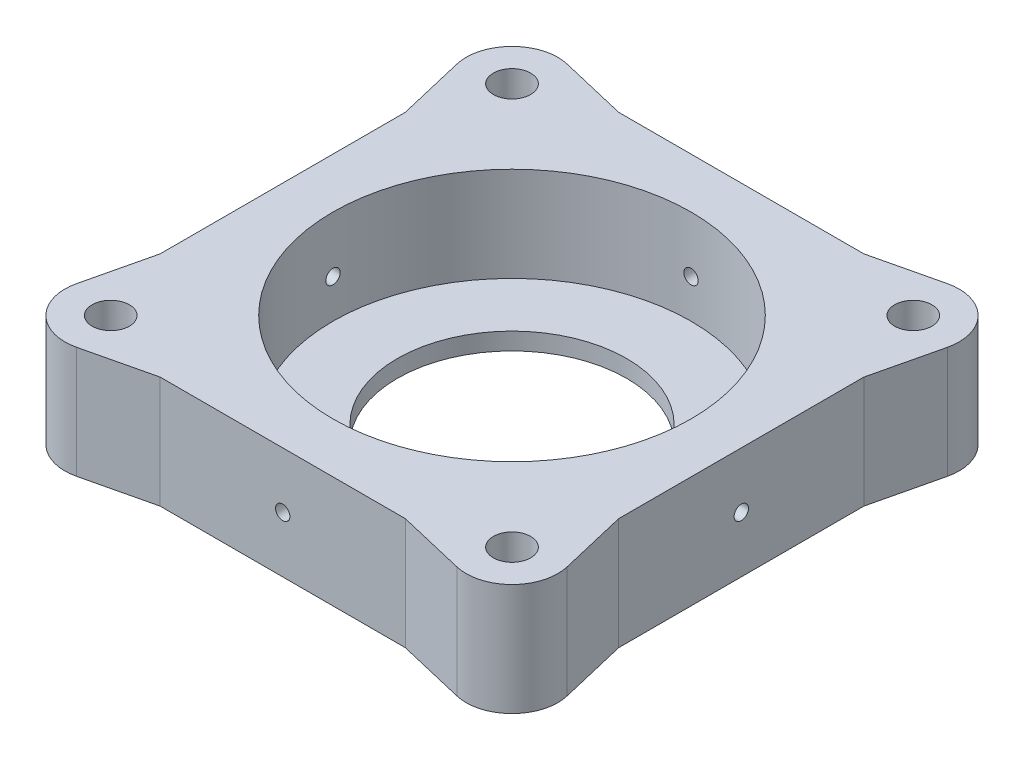
from build123d import *

# Parameters (mm, degrees)
SKETCH1_R           = 3.25
SKETCH1_R_2         = 20
BOSS_EXTRUDE1_DEPTH = 19.5
SKETCH2_R           = 31.25
CUT_EXTRUDE1_DEPTH  = 16.5
SKETCH3_R           = 5.25
CUT_EXTRUDE2_DEPTH  = 10
SKETCH4_R           = 1.25
CUT_EXTRUDE3_DEPTH  = 80
SKETCH5_R           = 1.25
CUT_EXTRUDE4_DEPTH  = 80


with BuildPart() as part:
    # Sketch1 → Boss-Extrude1 (new body)
    with BuildSketch(Plane(origin=(0, 0, 0), x_dir=(1, 0, 0), z_dir=(0, 1, 0))):
        with BuildLine():
            Line((-21.388284323, 40), (-33.157842357, 42.785014786))
            ThreePointArc((-33.157842357, 42.785014786), (-40.656854249, 40.656854249), (-42.785014786, 33.157842357))
            Line((-42.785014786, 33.157842357), (-40, 21.388284323))
            Line((-40, 21.388284323), (-40, -21.388284323))
            Line((-40, -21.388284323), (-42.785014786, -33.157842357))
            ThreePointArc((-42.785014786, -33.157842357), (-40.656854249, -40.656854249), (-33.157842357, -42.785014786))
            Line((-33.157842357, -42.785014786), (-21.388284323, -40))
            Line((-21.388284323, -40), (21.388284323, -40))
            Line((21.388284323, -40), (33.157842357, -42.785014786))
            ThreePointArc((33.157842357, -42.785014786), (40.656854249, -40.656854249), (42.785014786, -33.157842357))
            Line((42.785014786, -33.157842357), (40, -21.388284323))
            Line((40, -21.388284323), (40, 21.388284323))
            Line((40, 21.388284323), (42.785014786, 33.157842357))
            ThreePointArc((42.785014786, 33.157842357), (40.656854249, 40.656854249), (33.157842357, 42.785014786))
            Line((33.157842357, 42.785014786), (21.388284323, 40))
            Line((21.388284323, 40), (-21.388284323, 40))
        make_face()
        with Locations((35, 35)):
            Circle(SKETCH1_R, mode=Mode.SUBTRACT)
        with Locations((-35, -35)):
            Circle(SKETCH1_R, mode=Mode.SUBTRACT)
        with Locations((35, -35)):
            Circle(SKETCH1_R, mode=Mode.SUBTRACT)
        with Locations((-35, 35)):
            Circle(SKETCH1_R, mode=Mode.SUBTRACT)
        Circle(SKETCH1_R_2, mode=Mode.SUBTRACT)
    extrude(amount=BOSS_EXTRUDE1_DEPTH)

    # Sketch2 → Cut-Extrude1 (cut)
    with BuildSketch(Plane(origin=(0, 19.5, 0), x_dir=(1, 0, 0), z_dir=(0, 1, 0))):
        Circle(SKETCH2_R)
    extrude(amount=-CUT_EXTRUDE1_DEPTH, mode=Mode.SUBTRACT)

    # Sketch3 → Cut-Extrude2 (cut)
    with BuildSketch(Plane.XZ):
        with Locations((-35, 35)):
            Circle(SKETCH3_R)
        with Locations((35, 35)):
            Circle(SKETCH3_R)
        with Locations((35, -35)):
            Circle(SKETCH3_R)
        with Locations((-35, -35)):
            Circle(SKETCH3_R)
    extrude(amount=-CUT_EXTRUDE2_DEPTH, mode=Mode.SUBTRACT)

    # Sketch4 → Cut-Extrude3 (cut)
    with BuildSketch(Plane.XY.offset(40)):
        with Locations((0, 9.75)):
            Circle(SKETCH4_R)
    extrude(amount=-CUT_EXTRUDE3_DEPTH, mode=Mode.SUBTRACT)

    # Sketch5 → Cut-Extrude4 (cut)
    with BuildSketch(Plane(origin=(40, 0, 0), x_dir=(0, 0, -1), z_dir=(1, 0, 0))):
        with Locations((0, 9.75)):
            Circle(SKETCH5_R)
    extrude(amount=-CUT_EXTRUDE4_DEPTH, mode=Mode.SUBTRACT)


solid = part.part
